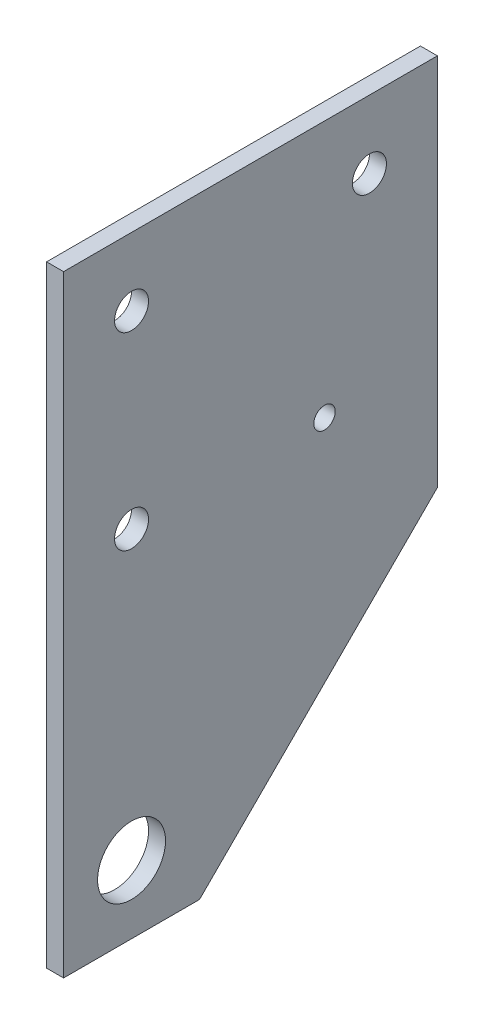
from build123d import *

# Parameters (mm, degrees)
SKETCH1_R           = 2
SKETCH1_R_2         = 6.35
SKETCH1_R_3         = 3.175
BOSS_EXTRUDE1_DEPTH = 3.175


with BuildPart() as part:
    # Sketch1 → Boss-Extrude1 (new body)
    with BuildSketch(Plane(origin=(0, 0, 0), x_dir=(0, 0, -1), z_dir=(1, 0, 0))):
        Polygon((-12.7, 101.6), (57.15, 101.6), (57.15, 31.75), (12.7, -12.7), (-12.7, -12.7), align=None)
        with Locations((36.0553, 53.601042741)):
            Circle(SKETCH1_R, mode=Mode.SUBTRACT)
        Circle(SKETCH1_R_2, mode=Mode.SUBTRACT)
        with Locations((0, 88.9)):
            Circle(SKETCH1_R_3, mode=Mode.SUBTRACT)
        with Locations((44.45, 88.9)):
            Circle(SKETCH1_R_3, mode=Mode.SUBTRACT)
        with Locations((0, 53.601042741)):
            Circle(SKETCH1_R_3, mode=Mode.SUBTRACT)
    extrude(amount=BOSS_EXTRUDE1_DEPTH)


solid = part.part
